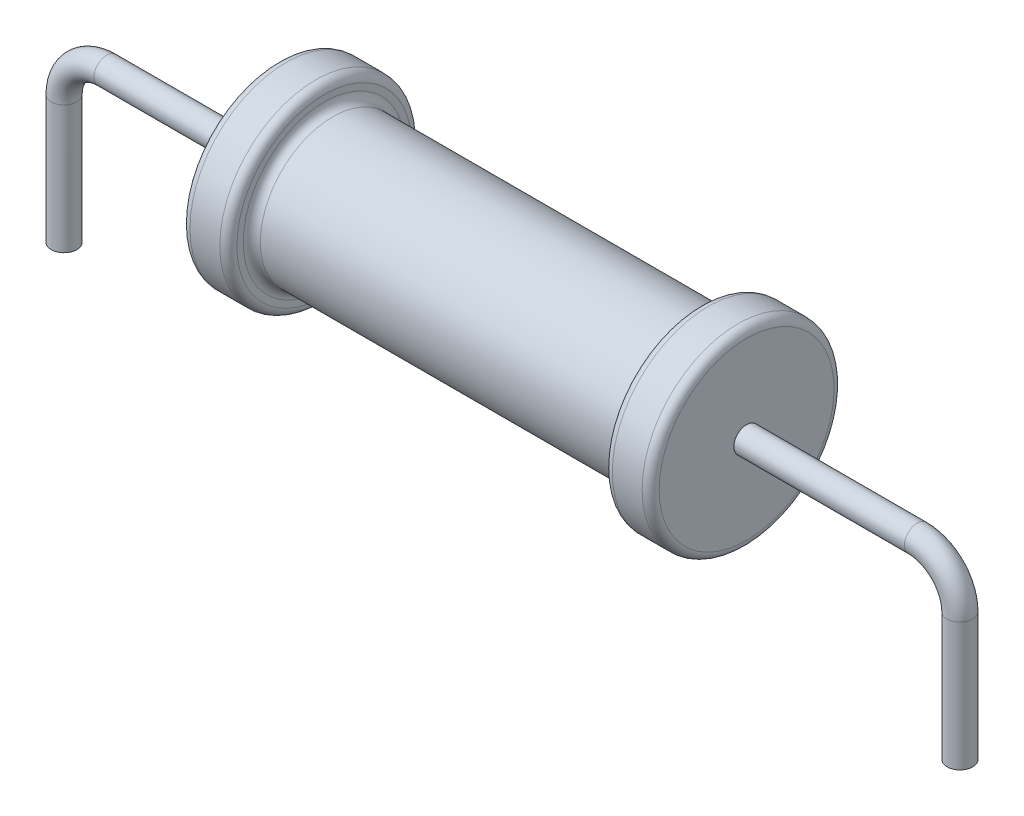
from build123d import *

# Parameters (mm, degrees)
SWEEP_4_PROFILE_R = 0.3
SWEEP_5_PROFILE_R = 0.3


with BuildPart() as part:
    # Эскиз2 → Повернуть7 (revolve)
    with BuildSketch(Plane(origin=(0, 0, 0), x_dir=(1, 0, 0), z_dir=(0, 1, 0))):
        with BuildLine():
            Line((-5.422047244, 0), (5.577952756, 0))
            Line((5.577952756, 0), (5.577952756, 2.05))
            ThreePointArc((5.577952756, 2.05), (5.519374112, 2.191421356), (5.377952756, 2.25))
            Line((5.377952756, 2.25), (4.677952756, 2.25))
            ThreePointArc((4.677952756, 2.25), (4.5365314, 2.191421356), (4.477952756, 2.05))
            Line((4.477952756, 2.05), (4.477952756, 1.9))
            ThreePointArc((4.477952756, 1.9), (4.419374112, 1.758578644), (4.277952756, 1.7))
            Line((4.277952756, 1.7), (-4.122047244, 1.7))
            ThreePointArc((-4.122047244, 1.7), (-4.2634686, 1.758578644), (-4.322047244, 1.9))
            Line((-4.322047244, 1.9), (-4.322047244, 2.05))
            ThreePointArc((-4.322047244, 2.05), (-4.380625888, 2.191421356), (-4.522047244, 2.25))
            Line((-4.522047244, 2.25), (-5.222047244, 2.25))
            ThreePointArc((-5.222047244, 2.25), (-5.3634686, 2.191421356), (-5.422047244, 2.05))
            Line((-5.422047244, 2.05), (-5.422047244, 0))
        make_face()
    revolve(axis=Axis((-5.422047244, 0, 0), (1, 0, 0)))

    # По траектории4: sweep along a path in Эскиз47
    with BuildLine(Plane.XY) as sweep_4_path:
        Line((-5.422047244, 0), (-9.422047244, 0))
        ThreePointArc((-9.422047244, 0), (-10.129154025, -0.292893219), (-10.422047244, -1))
        Line((-10.422047244, -1), (-10.422047244, -4))
    # По траектории4 profile (on start of the path) → По траектории4 (sweep)
    with BuildSketch(Plane(origin=(-5.422047244, 0, 0), x_dir=(0, -1, 0), z_dir=(-1, 0, 0))):
        Circle(SWEEP_4_PROFILE_R)
    sweep(path=sweep_4_path.line)

    # По траектории5: sweep along a path in Эскиз92
    with BuildLine(Plane.XY) as sweep_5_path:
        Line((5.577952756, 0), (9.577952756, 0))
        ThreePointArc((9.577952756, 0), (10.285059537, -0.292893219), (10.577952756, -1))
        Line((10.577952756, -1), (10.577952756, -4))
    # По траектории5 profile (on start of the path) → По траектории5 (sweep)
    with BuildSketch(Plane(origin=(5.577952756, 0, 0), x_dir=(0, 0, 1), z_dir=(1, 0, 0))):
        Circle(SWEEP_5_PROFILE_R)
    sweep(path=sweep_5_path.line)


solid = part.part
